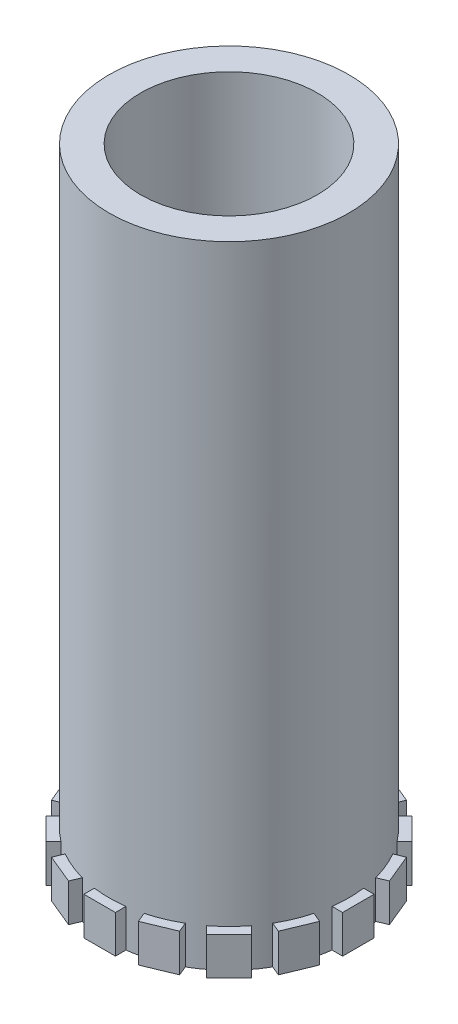
from build123d import *

# Parameters (mm, degrees)
SKETCH_1_R               = 9.5
SKETCH_1_R_2             = 7
EXTRUDE_1_DEPTH          = 50
SKETCH_2_W               = 1.5
SKETCH_2_H               = 2.5
EXTRUDE_2_DEPTH          = 3
PATTERN_CIRCULAR_1_COUNT = 16


with BuildPart() as part:
    # 草图1 → 凸台-拉伸1 (new body)
    with BuildSketch(Plane(origin=(0, 0, 0), x_dir=(1, 0, 0), z_dir=(0, 1, 0))):
        Circle(SKETCH_1_R)
        Circle(SKETCH_1_R_2, mode=Mode.SUBTRACT)
    extrude(amount=EXTRUDE_1_DEPTH)

    # 草图2 → 凸台-拉伸2 (add)
    with BuildSketch(Plane(origin=(0, 0, 0), x_dir=(-1, 0, 0), z_dir=(0, -1, 0))):
        with Locations((9.5, 0)):
            Rectangle(SKETCH_2_W, SKETCH_2_H)
    extrude_2 = extrude(amount=-EXTRUDE_2_DEPTH)

    # 阵列(圆周)1: 凸台-拉伸2 ×16 about axis
    pattern_circular_1_axis = Axis((0, 0, 0), (0, 1, 0))
    for i in range(1, PATTERN_CIRCULAR_1_COUNT):
        add(extrude_2.rotate(pattern_circular_1_axis, i * 360 / PATTERN_CIRCULAR_1_COUNT))


solid = part.part
